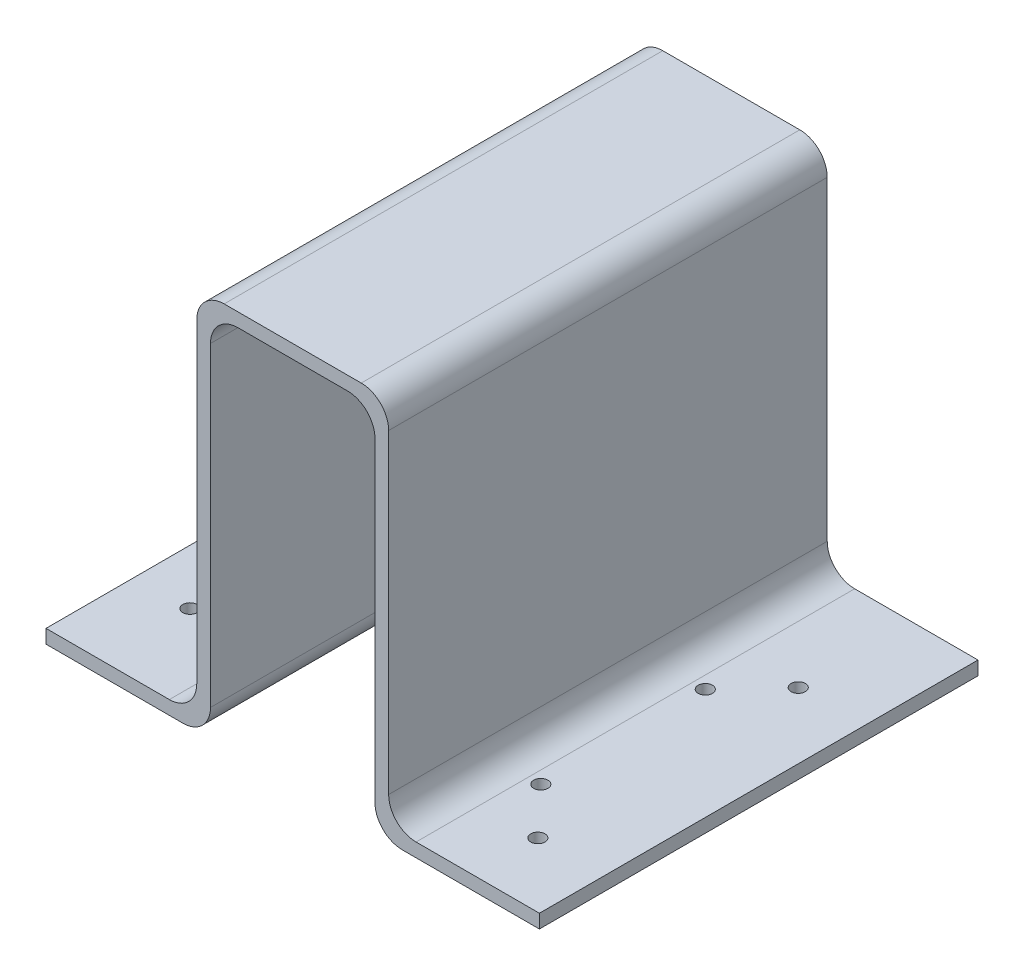
from build123d import *

# Parameters (mm, degrees)
EXTRUDE1_DEPTH     = 203.2
SKETCH3_R          = 3.302
CUT_EXTRUDE1_DEPTH = 6.35
SKETCH4_R          = 3.302
CUT_EXTRUDE2_DEPTH = 6.35


with BuildPart() as part:
    # Sketch1 → Extrude1 (new body)
    with BuildSketch(Plane.XY):
        with BuildLine():
            Line((0, 0), (63.5, 0))
            ThreePointArc((63.5, 0), (72.480256121, 3.719743879), (76.2, 12.7))
            Line((76.2, 12.7), (76.2, 158.75))
            ThreePointArc((76.2, 158.75), (79.919743879, 167.730256121), (88.9, 171.45))
            Line((88.9, 171.45), (139.7, 171.45))
            ThreePointArc((139.7, 171.45), (148.680256121, 167.730256121), (152.4, 158.75))
            Line((152.4, 158.75), (152.4, 12.7))
            ThreePointArc((152.4, 12.7), (156.119743879, 3.719743879), (165.1, 0))
            Line((165.1, 0), (228.6, 0))
            Line((228.6, 0), (228.6, 0.133258461))
            Line((228.6, 0.133258461), (228.6, 6.35))
            Line((228.6, 6.35), (171.45, 6.35))
            ThreePointArc((171.45, 6.35), (162.469743879, 10.069743879), (158.75, 19.05))
            Line((158.75, 19.05), (158.75, 165.1))
            ThreePointArc((158.75, 165.1), (155.030256121, 174.080256121), (146.05, 177.8))
            Line((146.05, 177.8), (82.55, 177.8))
            ThreePointArc((82.55, 177.8), (73.569743879, 174.080256121), (69.85, 165.1))
            Line((69.85, 165.1), (69.85, 19.05))
            ThreePointArc((69.85, 19.05), (66.130256121, 10.069743879), (57.15, 6.35))
            Line((57.15, 6.35), (0, 6.35))
            Line((0, 6.35), (0, 0))
        make_face()
    extrude(amount=EXTRUDE1_DEPTH)

    # Sketch3 → Cut-Extrude1 (cut)
    with BuildSketch(Plane(origin=(0, 6.35, 0), x_dir=(-1, 0, 0), z_dir=(0, 1, 0))):
        with Locations((-25.4, 41.275)):
            Circle(SKETCH3_R)
        with Locations((-50.8, 63.5)):
            Circle(SKETCH3_R)
        with Locations((-25.4, 161.925)):
            Circle(SKETCH3_R)
        with Locations((-50.8, 139.7)):
            Circle(SKETCH3_R)
    extrude(amount=-CUT_EXTRUDE1_DEPTH, mode=Mode.SUBTRACT)

    # Sketch4 → Cut-Extrude2 (cut)
    with BuildSketch(Plane(origin=(0, 6.35, 0), x_dir=(-1, 0, 0), z_dir=(0, 1, 0))):
        with Locations((-177.183969253, 74.931336249)):
            Circle(SKETCH4_R)
        with Locations((-177.183969253, 151.131336249)):
            Circle(SKETCH4_R)
        with Locations((-198.01776745, 52.706336249)):
            Circle(SKETCH4_R)
        with Locations((-198.01776745, 173.356336249)):
            Circle(SKETCH4_R)
    extrude(amount=-CUT_EXTRUDE2_DEPTH, mode=Mode.SUBTRACT)


solid = part.part
